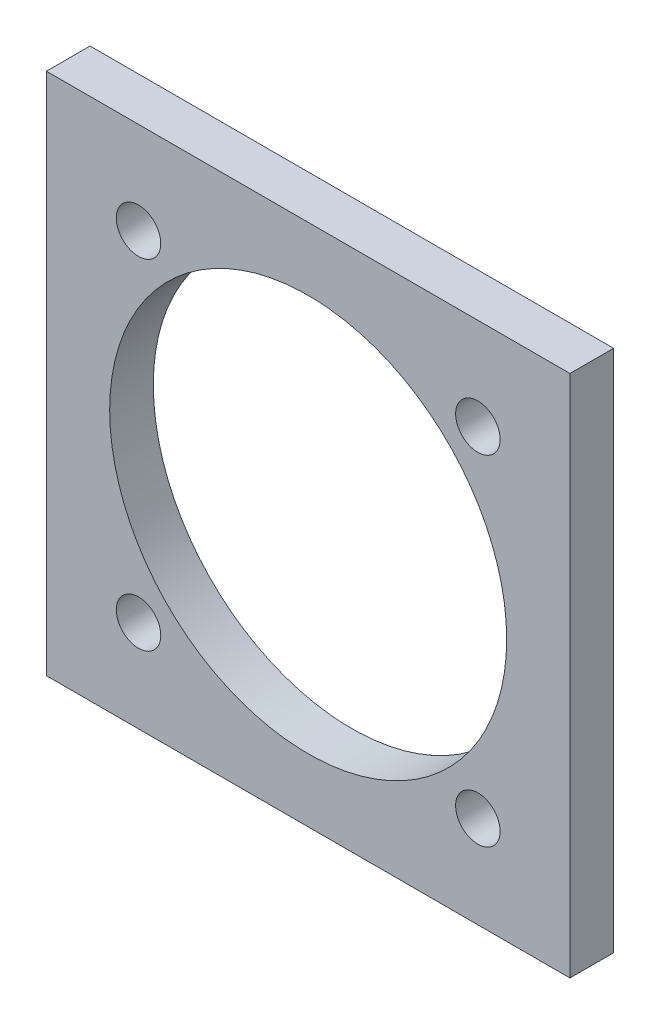
from build123d import *

# Parameters (mm, degrees)
IZIM1_W                     = 120
IZIM1_H                     = 120
IZIM1_R                     = 45.5
IZIM1_R_2                   = 5.1
Y_KSEKLIK_EKSTR_ZYON1_DEPTH = 10


with BuildPart() as part:
    # Çizim1 → Yükseklik-Ekstrüzyon1 (new body)
    with BuildSketch(Plane.XY):
        Rectangle(IZIM1_W, IZIM1_H)
        Circle(IZIM1_R, mode=Mode.SUBTRACT)
        with Locations((-38.890872965, 38.890872965)):
            Circle(IZIM1_R_2, mode=Mode.SUBTRACT)
        with Locations((38.890872965, 38.890872965)):
            Circle(IZIM1_R_2, mode=Mode.SUBTRACT)
        with Locations((38.890872965, -38.890872965)):
            Circle(IZIM1_R_2, mode=Mode.SUBTRACT)
        with Locations((-38.890872965, -38.890872965)):
            Circle(IZIM1_R_2, mode=Mode.SUBTRACT)
    extrude(amount=Y_KSEKLIK_EKSTR_ZYON1_DEPTH)


solid = part.part
